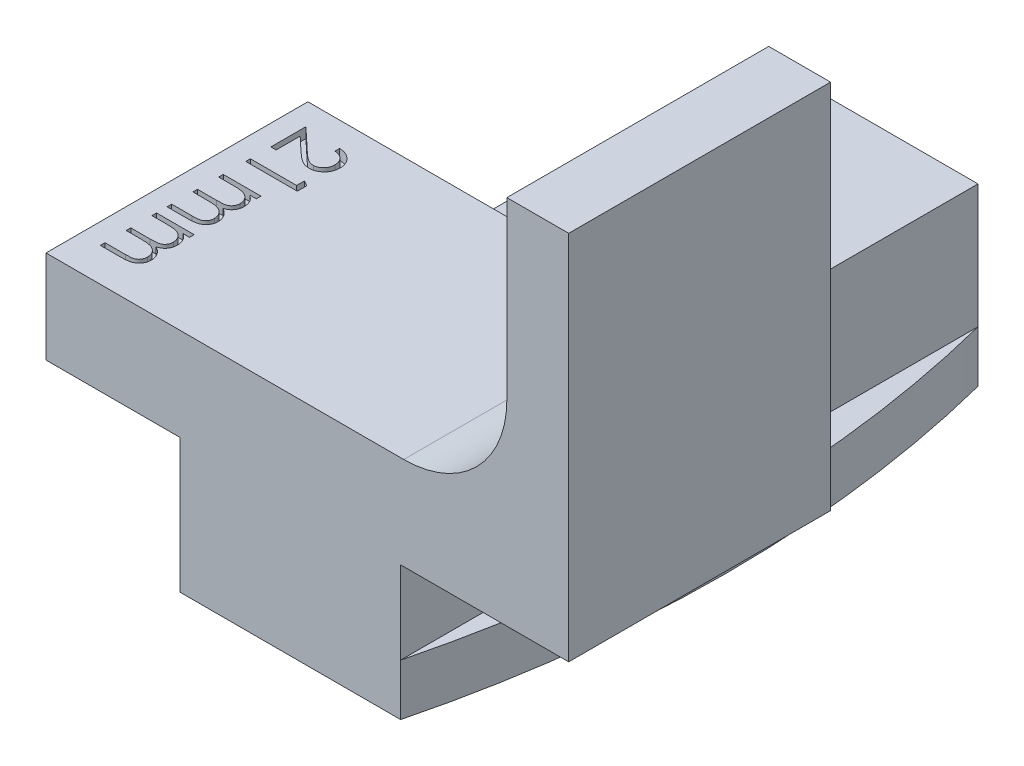
from build123d import *

# Parameters (mm, degrees)
BOSS_EXTRUDE1_DEPTH = 12.7
FILLET1_R           = 5
BOSS_EXTRUDE2_DEPTH = 28
SKETCH2_OUTSIDE_W   = 36.354
SKETCH2_OUTSIDE_H   = 39.004
CUT_EXTRUDE1_DEPTH  = 10
CUT_EXTRUDE2_DEPTH  = 0.5


with BuildPart() as part:
    # Sketch1 → Boss-Extrude1 (new body)
    with BuildSketch(Plane.XY):
        Polygon((0, 0), (0, -4), (-1.75, -4), (-1.75, -6.5), (12.45, -6.5), (12.45, -4), (10.7, -4), (10.7, 0), (18.85, 0), (18.85, 18), (15.85, 18), (15.85, 4.5), (-6.5, 4.5), (-6.5, 0), align=None)
    extrude(amount=BOSS_EXTRUDE1_DEPTH)

    # Fillet1
    fillet1_edges = [part.edges().sort_by_distance(p)[0] for p in [
        (15.85, 4.5, 6.35),
    ]]
    fillet(fillet1_edges, radius=FILLET1_R)

    # Sketch3 → Boss-Extrude2 (add)
    with BuildSketch(Plane.XY.offset(12.7)):
        Polygon((0, 0), (0, 2), (10.7, 2), (10.7, 0), (10.7, -4), (12.45, -4), (12.45, -6.5), (-1.75, -6.5), (-1.75, -4), (0, -4), align=None)
    extrude(amount=-BOSS_EXTRUDE2_DEPTH)

    # Sketch2 outside → Cut-Extrude1 (cut)
    with BuildSketch(Plane(origin=(0, -4, 0), x_dir=(1, 0, 0), z_dir=(0, 1, 0))):
        with Locations((6.175, 1.3)):
            Rectangle(SKETCH2_OUTSIDE_W, SKETCH2_OUTSIDE_H)
        with BuildLine():
            Line((0, 15.3), (10.7, 15.3))
            ThreePointArc((10.7, 15.3), (12.45, 1.3), (10.7, -12.7))
            Line((10.7, -12.7), (0, -12.7))
            ThreePointArc((0, -12.7), (-1.75, 1.3), (0, 15.3))
        make_face(mode=Mode.SUBTRACT)
    extrude(amount=-CUT_EXTRUDE1_DEPTH, mode=Mode.SUBTRACT)

    # Sketch4 → Cut-Extrude2 (cut)
    with BuildSketch(Plane(origin=(0, 4.5, 0), x_dir=(1, 0, 0), z_dir=(0, 1, 0))):
        with BuildLine():
            Line((-3.769230769, -1.416666667), (-3.769230769, -1.192307692))
            add(Edge.make_bspline(
                [(-3.769230769, -1.192307692), (-3.739465703, -1.193769696), (-3.681007904, -1.196641031), (-3.595778619, -1.210093331), (-3.514303391, -1.229324068), (-3.437280723, -1.25657851), (-3.363790512, -1.290235363), (-3.294808625, -1.331441091), (-3.229650424, -1.379317255), (-3.169549571, -1.433776024), (-3.114609876, -1.492868808), (-3.06666458, -1.556241548), (-3.026618971, -1.623242893), (-2.992959714, -1.693291702), (-2.967725032, -1.76719811), (-2.948993088, -1.844255655), (-2.93772487, -1.924812628), (-2.936513511, -1.979698296), (-2.935897436, -2.007612179)],
                knots=[0, 0, 0, 0, 8.9345e-05, 0.000175471, 0.000258432, 0.000340159, 0.000420153, 0.000500544, 0.000580775, 0.000662333, 0.000743489, 0.000822516, 0.000900244, 0.000977304, 0.001055226, 0.001134057, 0.001214939, 0.001298647, 0.001298647, 0.001298647, 0.001298647], degree=3))
            add(Edge.make_bspline(
                [(-2.935897436, -2.007612179), (-2.936539191, -2.03502509), (-2.937800215, -2.088890479), (-2.948629522, -2.167506203), (-2.965590659, -2.242347128), (-2.989387385, -2.313266961), (-3.021376262, -2.379699864), (-3.059803075, -2.442144896), (-3.104245812, -2.501345475), (-3.156569964, -2.554636035), (-3.21242881, -2.603570377), (-3.272063027, -2.645786274), (-3.333655374, -2.681938533), (-3.397675518, -2.712072591), (-3.464726252, -2.734255547), (-3.533831397, -2.751097124), (-3.605706262, -2.760616705), (-3.654353802, -2.762077722), (-3.679086538, -2.762820513)],
                knots=[0, 0, 0, 0, 8.2206e-05, 0.000161532, 0.000237582, 0.000312174, 0.000385423, 0.000458258, 0.000531878, 0.000606964, 0.000681872, 0.000754411, 0.000825787, 0.000895917, 0.000966233, 0.001037292, 0.001109039, 0.001183241, 0.001183241, 0.001183241, 0.001183241], degree=3))
            add(Edge.make_bspline(
                [(-3.679086538, -2.762820513), (-3.71390642, -2.761611039), (-3.782935144, -2.759213317), (-3.884374332, -2.738703048), (-3.982655346, -2.706669826), (-4.061753419, -2.668100285), (-4.125491628, -2.629191397), (-4.177969275, -2.594128891), (-4.234473181, -2.553082598), (-4.294814136, -2.505455099), (-4.359464783, -2.452231619), (-4.428386065, -2.392930074), (-4.500865901, -2.327127586), (-4.550369902, -2.280942943), (-4.576021635, -2.257011218)],
                knots=[0, 0, 0, 0, 0.00010437, 0.000206908, 0.000309214, 0.000413814, 0.000469985, 0.000533183, 0.000603103, 0.000679442, 0.000763763, 0.000854314, 0.000952177, 0.001057422, 0.001057422, 0.001057422, 0.001057422], degree=3))
            Line((-4.576021635, -2.257011218), (-5.243589744, -1.631510417))
            Line((-5.243589744, -1.631510417), (-5.243589744, -2.794871795))
            Line((-5.243589744, -2.794871795), (-5.5, -2.794871795))
            Line((-5.5, -2.794871795), (-5.5, -1.096153846))
            Line((-5.5, -1.096153846), (-4.465344551, -2.065705128))
            add(Edge.make_bspline(
                [(-4.465344551, -2.065705128), (-4.440704248, -2.089312433), (-4.393375267, -2.134657234), (-4.324255471, -2.198765658), (-4.260207374, -2.256437951), (-4.200947164, -2.307712368), (-4.146810791, -2.352631099), (-4.097374002, -2.391050425), (-4.053061049, -2.42314015), (-4.001004044, -2.457148572), (-3.937370093, -2.489577858), (-3.85999724, -2.518079883), (-3.780171816, -2.535334621), (-3.726244495, -2.53741506), (-3.69911859, -2.538461538)],
                knots=[0, 0, 0, 0, 0.000102371, 0.000196633, 0.000282807, 0.00036092, 0.00043171, 0.000493817, 0.000548716, 0.000595807, 0.000680247, 0.000762311, 0.000842655, 0.000923972, 0.000923972, 0.000923972, 0.000923972], degree=3))
            add(Edge.make_bspline(
                [(-3.69911859, -2.538461538), (-3.682058563, -2.538012101), (-3.648436526, -2.537126347), (-3.599173745, -2.529161064), (-3.551469794, -2.517458483), (-3.5059145, -2.49942119), (-3.461611877, -2.477750046), (-3.419908864, -2.450063563), (-3.379383905, -2.418425182), (-3.341426566, -2.381726212), (-3.30665175, -2.341437563), (-3.275849492, -2.298868859), (-3.250107098, -2.253833431), (-3.229004646, -2.206518962), (-3.21245079, -2.157057938), (-3.200980379, -2.105354542), (-3.193778604, -2.051551675), (-3.192804196, -2.014813464), (-3.192307692, -1.99609375)],
                knots=[0, 0, 0, 0, 5.1143e-05, 0.000100793, 0.000149379, 0.000198206, 0.000247478, 0.000297068, 0.000348064, 0.000401546, 0.00045516, 0.000507556, 0.000558926, 0.000610487, 0.000662748, 0.000715112, 0.000769155, 0.0008253, 0.0008253, 0.0008253, 0.0008253], degree=3))
            add(Edge.make_bspline(
                [(-3.192307692, -1.99609375), (-3.192818275, -1.976543068), (-3.193820976, -1.938148758), (-3.200839356, -1.881779251), (-3.212935551, -1.827999215), (-3.229519178, -1.776699782), (-3.250398096, -1.727831527), (-3.276905454, -1.681836316), (-3.308006308, -1.638294229), (-3.343459583, -1.597285236), (-3.383118274, -1.559604405), (-3.426783108, -1.525801638), (-3.474738119, -1.496971452), (-3.525900148, -1.471414789), (-3.581629531, -1.451860159), (-3.640575816, -1.43514505), (-3.703576488, -1.423002759), (-3.746982525, -1.418813776), (-3.769230769, -1.416666667)],
                knots=[0, 0, 0, 0, 5.8647e-05, 0.000115173, 0.000170091, 0.000223779, 0.000276715, 0.000329204, 0.000382705, 0.000437025, 0.000491578, 0.000546571, 0.000602313, 0.000659202, 0.000717819, 0.000779181, 0.000842925, 0.000909953, 0.000909953, 0.000909953, 0.000909953], degree=3))
        make_face()
        Polygon((-3, -3.550580929), (-3, -4.012820513), (-5.5, -4.012820513), (-5.5, -3.788461538), (-3.256410256, -3.788461538), (-3.256410256, -3.403846154), align=None)
        with BuildLine():
            Line((-3.673076923, -5.102564103), (-3.673076923, -5.326923077))
            Line((-3.673076923, -5.326923077), (-3.990584936, -5.326923077))
            add(Edge.make_bspline(
                [(-3.990584936, -5.326923077), (-3.962849174, -5.34716972), (-3.90979484, -5.385898498), (-3.839103141, -5.448797063), (-3.780096742, -5.512713891), (-3.748715772, -5.558420094), (-3.733673878, -5.580328526)],
                knots=[0, 0, 0, 0, 0.000102966, 0.000196958, 0.000283467, 0.000363109, 0.000363109, 0.000363109, 0.000363109], degree=3))
            add(Edge.make_bspline(
                [(-3.733673878, -5.580328526), (-3.719384332, -5.610231856), (-3.691054893, -5.66951607), (-3.662316637, -5.763386945), (-3.64465585, -5.85944028), (-3.642240584, -5.92430329), (-3.641025641, -5.95693109)],
                knots=[0, 0, 0, 0, 9.9308e-05, 0.000196881, 0.000293544, 0.000391385, 0.000391385, 0.000391385, 0.000391385], degree=3))
            add(Edge.make_bspline(
                [(-3.641025641, -5.95693109), (-3.641774259, -5.978996712), (-3.643255733, -6.022663392), (-3.652841119, -6.087378046), (-3.669609496, -6.150240939), (-3.692373764, -6.210844306), (-3.720823163, -6.267595926), (-3.753536683, -6.319722966), (-3.790488617, -6.366585325), (-3.833109774, -6.408107089), (-3.882637794, -6.445441216), (-3.940397397, -6.479783522), (-4.007688759, -6.511515734), (-4.056521976, -6.529102395), (-4.082231571, -6.538361378)],
                knots=[0, 0, 0, 0, 6.6199e-05, 0.000131004, 0.000195748, 0.000261045, 0.000324875, 0.00038587, 0.00044539, 0.00050347, 0.000563868, 0.000631031, 0.000704732, 0.000786676, 0.000786676, 0.000786676, 0.000786676], degree=3))
            add(Edge.make_bspline(
                [(-4.082231571, -6.538361378), (-4.064571271, -6.548155129), (-4.029818282, -6.567427856), (-3.980633806, -6.599789024), (-3.934628967, -6.633694597), (-3.891767192, -6.669433505), (-3.852260399, -6.706879695), (-3.815977042, -6.746209064), (-3.782764696, -6.787198937), (-3.743952279, -6.844189786), (-3.702887596, -6.918231383), (-3.666820915, -7.011609342), (-3.644996157, -7.10893871), (-3.642355706, -7.17510418), (-3.641025641, -7.208433494)],
                knots=[0, 0, 0, 0, 6.0564e-05, 0.000119181, 0.000176474, 0.000231939, 0.000286492, 0.000339652, 0.000392367, 0.000444597, 0.000546357, 0.000645594, 0.000744022, 0.000843928, 0.000843928, 0.000843928, 0.000843928], degree=3))
            add(Edge.make_bspline(
                [(-3.641025641, -7.208433494), (-3.642180799, -7.23906311), (-3.644441555, -7.299008243), (-3.662194036, -7.386277718), (-3.692678069, -7.467664722), (-3.734273524, -7.543005491), (-3.786544369, -7.610976786), (-3.848736396, -7.670059864), (-3.920409698, -7.719895838), (-3.987832547, -7.752452009), (-4.047357785, -7.774534341), (-4.098076565, -7.788149508), (-4.153899102, -7.800177862), (-4.214892146, -7.810164466), (-4.281271152, -7.817463431), (-4.352927492, -7.822871085), (-4.429916858, -7.826531138), (-4.483035072, -7.826789761), (-4.510416667, -7.826923077)],
                knots=[0, 0, 0, 0, 9.1843e-05, 0.000179747, 0.000265793, 0.000351646, 0.00043699, 0.000522005, 0.000607999, 0.000697811, 0.000745818, 0.000798306, 0.00085518, 0.000917093, 0.000983624, 0.00105545, 0.001132653, 0.001214791, 0.001214791, 0.001214791, 0.001214791], degree=3))
            Line((-4.510416667, -7.826923077), (-5.5, -7.826923077))
            Line((-5.5, -7.826923077), (-5.5, -7.602564103))
            Line((-5.5, -7.602564103), (-4.509415064, -7.602564103))
            add(Edge.make_bspline(
                [(-4.509415064, -7.602564103), (-4.486043226, -7.602508472), (-4.441126106, -7.602401558), (-4.37666007, -7.600477536), (-4.317896958, -7.596852311), (-4.264916893, -7.592613284), (-4.217596337, -7.586724846), (-4.176030302, -7.579120619), (-4.139891931, -7.571065101), (-4.09983021, -7.557682379), (-4.055638935, -7.536290165), (-4.007972189, -7.503709763), (-3.966512436, -7.462646464), (-3.930306263, -7.415180793), (-3.901462215, -7.361006762), (-3.880083749, -7.301550172), (-3.867445823, -7.237011557), (-3.866083249, -7.192297345), (-3.865384615, -7.169370994)],
                knots=[0, 0, 0, 0, 7.0114e-05, 0.000134748, 0.000193447, 0.000246723, 0.00029418, 0.00033642, 0.000373469, 0.000405143, 0.000462933, 0.000520167, 0.000577538, 0.000637235, 0.000698627, 0.000760882, 0.000826196, 0.000894922, 0.000894922, 0.000894922, 0.000894922], degree=3))
            add(Edge.make_bspline(
                [(-3.865384615, -7.169370994), (-3.866418184, -7.141041216), (-3.868466848, -7.084888039), (-3.888606496, -7.003053701), (-3.919724694, -6.924627707), (-3.964153253, -6.851718167), (-4.017610819, -6.784563992), (-4.081140155, -6.726776322), (-4.15302033, -6.679039661), (-4.219553274, -6.646715238), (-4.279317224, -6.626294332), (-4.331529618, -6.612810815), (-4.390873599, -6.60232268), (-4.456950377, -6.592486587), (-4.530214792, -6.586066782), (-4.610327936, -6.58023223), (-4.697530764, -6.577503042), (-4.757978398, -6.577121286), (-4.789362981, -6.576923077)],
                knots=[0, 0, 0, 0, 8.4849e-05, 0.00016818, 0.000251319, 0.00033712, 0.000423311, 0.000508035, 0.000593596, 0.0006814, 0.000729071, 0.000782881, 0.000842994, 0.000909781, 0.000983233, 0.001063551, 0.001150742, 0.001244898, 0.001244898, 0.001244898, 0.001244898], degree=3))
            Line((-4.789362981, -6.576923077), (-5.5, -6.576923077))
            Line((-5.5, -6.576923077), (-5.5, -6.352564103))
            Line((-5.5, -6.352564103), (-4.571013622, -6.352564103))
            add(Edge.make_bspline(
                [(-4.571013622, -6.352564103), (-4.544803812, -6.352509908), (-4.494378771, -6.352405644), (-4.42207291, -6.350460515), (-4.356287876, -6.34693718), (-4.29718885, -6.342386504), (-4.24461523, -6.337447467), (-4.198739476, -6.329631306), (-4.159370692, -6.321483736), (-4.115774829, -6.3090498), (-4.068483866, -6.287513236), (-4.017684108, -6.25475381), (-3.972914287, -6.214057471), (-3.934949709, -6.165705663), (-3.90383078, -6.111106833), (-3.881062877, -6.051037003), (-3.867930796, -5.985875666), (-3.866249348, -5.940965122), (-3.865384615, -5.91786859)],
                knots=[0, 0, 0, 0, 7.8627e-05, 0.000151271, 0.00021697, 0.000276236, 0.000329108, 0.000375296, 0.000415765, 0.000449679, 0.000511104, 0.000570834, 0.000630394, 0.000691713, 0.000754513, 0.000818227, 0.000883639, 0.000952896, 0.000952896, 0.000952896, 0.000952896], degree=3))
            add(Edge.make_bspline(
                [(-3.865384615, -5.91786859), (-3.866477801, -5.890714153), (-3.868656482, -5.836596325), (-3.888266677, -5.757094916), (-3.918983875, -5.680319438), (-3.961598025, -5.607494611), (-4.014383105, -5.540584666), (-4.076465083, -5.482006737), (-4.147071879, -5.432764324), (-4.212902559, -5.400091429), (-4.271171658, -5.379037283), (-4.320699289, -5.364983294), (-4.375763388, -5.353197643), (-4.436243472, -5.343207902), (-4.50226507, -5.335690764), (-4.573641592, -5.331193303), (-4.65059847, -5.327239971), (-4.703719911, -5.327031299), (-4.731270032, -5.326923077)],
                knots=[0, 0, 0, 0, 8.1352e-05, 0.000162132, 0.000244155, 0.000328761, 0.000414326, 0.000498997, 0.000583882, 0.000671677, 0.000718571, 0.000769613, 0.000825997, 0.000887416, 0.00095345, 0.001025239, 0.001101942, 0.00118458, 0.00118458, 0.00118458, 0.00118458], degree=3))
            Line((-4.731270032, -5.326923077), (-5.5, -5.326923077))
            Line((-5.5, -5.326923077), (-5.5, -5.102564103))
            Line((-5.5, -5.102564103), (-3.673076923, -5.102564103))
        make_face()
        with BuildLine():
            Line((-3.673076923, -8.33974359), (-3.673076923, -8.564102564))
            Line((-3.673076923, -8.564102564), (-3.990584936, -8.564102564))
            add(Edge.make_bspline(
                [(-3.990584936, -8.564102564), (-3.962849174, -8.584349207), (-3.90979484, -8.623077985), (-3.839103141, -8.68597655), (-3.780096742, -8.749893378), (-3.748715772, -8.795599581), (-3.733673878, -8.817508013)],
                knots=[0, 0, 0, 0, 0.000102966, 0.000196958, 0.000283467, 0.000363109, 0.000363109, 0.000363109, 0.000363109], degree=3))
            add(Edge.make_bspline(
                [(-3.733673878, -8.817508013), (-3.719384332, -8.847411343), (-3.691054893, -8.906695557), (-3.662316637, -9.000566432), (-3.64465585, -9.096619767), (-3.642240584, -9.161482777), (-3.641025641, -9.194110577)],
                knots=[0, 0, 0, 0, 9.9308e-05, 0.000196881, 0.000293544, 0.000391385, 0.000391385, 0.000391385, 0.000391385], degree=3))
            add(Edge.make_bspline(
                [(-3.641025641, -9.194110577), (-3.641774259, -9.216176199), (-3.643255733, -9.25984288), (-3.652841119, -9.324557533), (-3.669609496, -9.387420426), (-3.692373764, -9.448023794), (-3.720823163, -9.504775413), (-3.753536683, -9.556902453), (-3.790488617, -9.603764812), (-3.833109774, -9.645286576), (-3.882637794, -9.682620703), (-3.940397397, -9.716963009), (-4.007688759, -9.748695221), (-4.056521976, -9.766281882), (-4.082231571, -9.775540865)],
                knots=[0, 0, 0, 0, 6.6199e-05, 0.000131004, 0.000195748, 0.000261045, 0.000324875, 0.00038587, 0.00044539, 0.00050347, 0.000563868, 0.000631031, 0.000704732, 0.000786676, 0.000786676, 0.000786676, 0.000786676], degree=3))
            add(Edge.make_bspline(
                [(-4.082231571, -9.775540865), (-4.064571271, -9.785334616), (-4.029818282, -9.804607343), (-3.980633806, -9.836968511), (-3.934628967, -9.870874084), (-3.891767192, -9.906612993), (-3.852260399, -9.944059182), (-3.815977042, -9.983388551), (-3.782764696, -10.024378424), (-3.743952279, -10.081369273), (-3.702887596, -10.15541087), (-3.666820915, -10.24878883), (-3.644996157, -10.346118198), (-3.642355706, -10.412283667), (-3.641025641, -10.445612981)],
                knots=[0, 0, 0, 0, 6.0564e-05, 0.000119181, 0.000176474, 0.000231939, 0.000286492, 0.000339652, 0.000392367, 0.000444597, 0.000546357, 0.000645594, 0.000744022, 0.000843928, 0.000843928, 0.000843928, 0.000843928], degree=3))
            add(Edge.make_bspline(
                [(-3.641025641, -10.445612981), (-3.642180799, -10.476242597), (-3.644441555, -10.53618773), (-3.662194036, -10.623457206), (-3.692678069, -10.704844209), (-3.734273524, -10.780184978), (-3.786544369, -10.848156273), (-3.848736396, -10.907239351), (-3.920409698, -10.957075325), (-3.987832547, -10.989631496), (-4.047357785, -11.011713828), (-4.098076565, -11.025328995), (-4.153899102, -11.037357349), (-4.214892146, -11.047343953), (-4.281271152, -11.054642919), (-4.352927492, -11.060050572), (-4.429916858, -11.063710625), (-4.483035072, -11.063969248), (-4.510416667, -11.064102564)],
                knots=[0, 0, 0, 0, 9.1843e-05, 0.000179747, 0.000265793, 0.000351646, 0.00043699, 0.000522005, 0.000607999, 0.000697811, 0.000745818, 0.000798306, 0.00085518, 0.000917093, 0.000983624, 0.00105545, 0.001132653, 0.001214791, 0.001214791, 0.001214791, 0.001214791], degree=3))
            Line((-4.510416667, -11.064102564), (-5.5, -11.064102564))
            Line((-5.5, -11.064102564), (-5.5, -10.83974359))
            Line((-5.5, -10.83974359), (-4.509415064, -10.83974359))
            add(Edge.make_bspline(
                [(-4.509415064, -10.83974359), (-4.486043226, -10.839687959), (-4.441126106, -10.839581045), (-4.37666007, -10.837657023), (-4.317896958, -10.834031798), (-4.264916893, -10.829792772), (-4.217596337, -10.823904333), (-4.176030302, -10.816300107), (-4.139891931, -10.808244588), (-4.09983021, -10.794861866), (-4.055638935, -10.773469652), (-4.007972189, -10.74088925), (-3.966512436, -10.699825951), (-3.930306263, -10.65236028), (-3.901462215, -10.598186249), (-3.880083749, -10.53872966), (-3.867445823, -10.474191045), (-3.866083249, -10.429476832), (-3.865384615, -10.406550481)],
                knots=[0, 0, 0, 0, 7.0114e-05, 0.000134748, 0.000193447, 0.000246723, 0.00029418, 0.00033642, 0.000373469, 0.000405143, 0.000462933, 0.000520167, 0.000577538, 0.000637235, 0.000698627, 0.000760882, 0.000826196, 0.000894922, 0.000894922, 0.000894922, 0.000894922], degree=3))
            add(Edge.make_bspline(
                [(-3.865384615, -10.406550481), (-3.866418184, -10.378220703), (-3.868466848, -10.322067526), (-3.888606496, -10.240233188), (-3.919724694, -10.161807194), (-3.964153253, -10.088897654), (-4.017610819, -10.021743479), (-4.081140155, -9.96395581), (-4.15302033, -9.916219148), (-4.219553274, -9.883894726), (-4.279317224, -9.863473819), (-4.331529618, -9.849990302), (-4.390873599, -9.839502167), (-4.456950377, -9.829666074), (-4.530214792, -9.823246269), (-4.610327936, -9.817411717), (-4.697530764, -9.814682529), (-4.757978398, -9.814300773), (-4.789362981, -9.814102564)],
                knots=[0, 0, 0, 0, 8.4849e-05, 0.00016818, 0.000251319, 0.00033712, 0.000423311, 0.000508035, 0.000593596, 0.0006814, 0.000729071, 0.000782881, 0.000842994, 0.000909781, 0.000983233, 0.001063551, 0.001150742, 0.001244898, 0.001244898, 0.001244898, 0.001244898], degree=3))
            Line((-4.789362981, -9.814102564), (-5.5, -9.814102564))
            Line((-5.5, -9.814102564), (-5.5, -9.58974359))
            Line((-5.5, -9.58974359), (-4.571013622, -9.58974359))
            add(Edge.make_bspline(
                [(-4.571013622, -9.58974359), (-4.544803812, -9.589689396), (-4.494378771, -9.589585131), (-4.42207291, -9.587640002), (-4.356287876, -9.584116667), (-4.29718885, -9.579565992), (-4.24461523, -9.574626954), (-4.198739476, -9.566810793), (-4.159370692, -9.558663223), (-4.115774829, -9.546229287), (-4.068483866, -9.524692723), (-4.017684108, -9.491933297), (-3.972914287, -9.451236958), (-3.934949709, -9.40288515), (-3.90383078, -9.34828632), (-3.881062877, -9.28821649), (-3.867930796, -9.223055153), (-3.866249348, -9.178144609), (-3.865384615, -9.155048077)],
                knots=[0, 0, 0, 0, 7.8627e-05, 0.000151271, 0.00021697, 0.000276236, 0.000329108, 0.000375296, 0.000415765, 0.000449679, 0.000511104, 0.000570834, 0.000630394, 0.000691713, 0.000754513, 0.000818227, 0.000883639, 0.000952896, 0.000952896, 0.000952896, 0.000952896], degree=3))
            add(Edge.make_bspline(
                [(-3.865384615, -9.155048077), (-3.866477801, -9.12789364), (-3.868656482, -9.073775813), (-3.888266677, -8.994274403), (-3.918983875, -8.917498926), (-3.961598025, -8.844674098), (-4.014383105, -8.777764153), (-4.076465083, -8.719186224), (-4.147071879, -8.669943811), (-4.212902559, -8.637270916), (-4.271171658, -8.61621677), (-4.320699289, -8.602162781), (-4.375763388, -8.59037713), (-4.436243472, -8.580387389), (-4.50226507, -8.572870251), (-4.573641592, -8.56837279), (-4.65059847, -8.564419458), (-4.703719911, -8.564210786), (-4.731270032, -8.564102564)],
                knots=[0, 0, 0, 0, 8.1352e-05, 0.000162132, 0.000244155, 0.000328761, 0.000414326, 0.000498997, 0.000583882, 0.000671677, 0.000718571, 0.000769613, 0.000825997, 0.000887416, 0.00095345, 0.001025239, 0.001101942, 0.00118458, 0.00118458, 0.00118458, 0.00118458], degree=3))
            Line((-4.731270032, -8.564102564), (-5.5, -8.564102564))
            Line((-5.5, -8.564102564), (-5.5, -8.33974359))
            Line((-5.5, -8.33974359), (-3.673076923, -8.33974359))
        make_face()
    extrude(amount=-CUT_EXTRUDE2_DEPTH, mode=Mode.SUBTRACT)


solid = part.part
